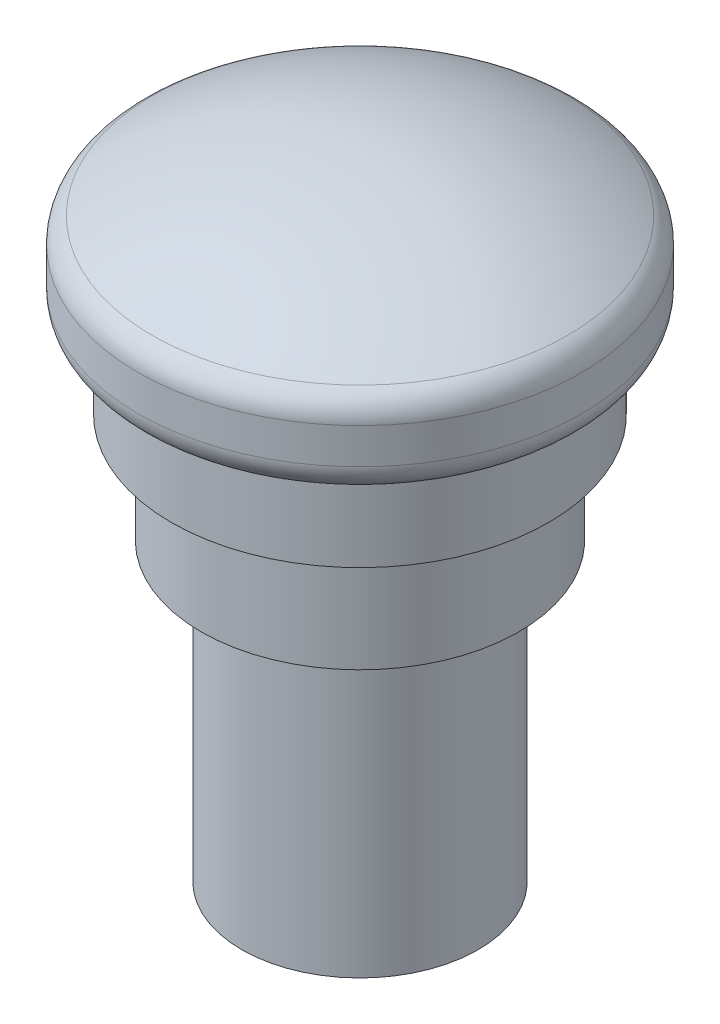
from build123d import *

# Parameters (mm, degrees)
FILLET1_R = 2


with BuildPart() as part:
    # Sketch1 → Revolve1 (revolve)
    with BuildSketch(Plane(origin=(0, 0, 0), x_dir=(0, 0, -1), z_dir=(1, 0, 0))):
        with BuildLine():
            Line((15, 38.4), (15, 32.9))
            Line((15, 32.9), (12.75, 32.9))
            Line((12.75, 32.9), (12.75, 27.4))
            Line((12.75, 27.4), (10.75, 27.4))
            Line((10.75, 27.4), (10.75, 20))
            Line((10.75, 20), (8, 20))
            Line((8, 20), (8, 0))
            Line((8, 0), (0, 0))
            Line((0, 0), (0, 43))
            ThreePointArc((0, 43), (7.844743463, 41.824163466), (15, 38.4))
        make_face()
    revolve(axis=Axis((0, 43, 0), (0, -1, 0)))

    # Fillet1
    fillet1_edges = [part.edges().sort_by_distance(p)[0] for p in [
        (0, 32.9, 15),
        (0, 38.4, 15),
    ]]
    fillet(fillet1_edges, radius=FILLET1_R)


solid = part.part
